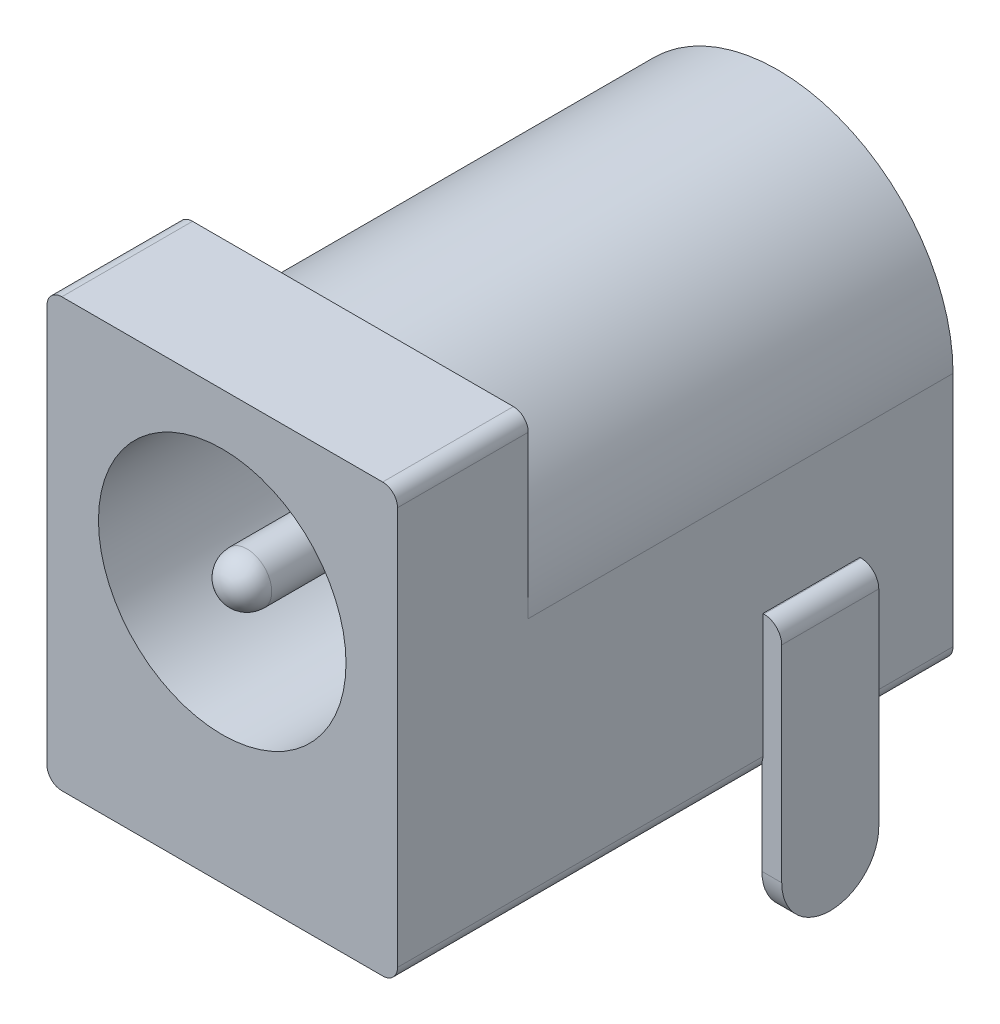
from build123d import *

# Parameters (mm, degrees)
BASE_EXTRUDE_DEPTH       = 14.2494
SKETCH2_R                = 3.175
SKETCH2_R_2              = 0.635
CUT_EXTRUDE1_DEPTH       = 11.7094
FILLET1_R                = 0.635
CUT_EXTRUDE2_DEPTH       = 10.8966
SKETCH4_W                = 0.508
SKETCH4_H                = 2.4892
SKETCH4_W_2              = 2.9972
SKETCH4_H_2              = 0.508
SKETCH4_W_3              = 2.4892
SKETCH4_H_3              = 0.254
BOSS_EXTRUDE1_DEPTH      = 3.683
BOSS_EXTRUDE1_DEPTH_BACK = 3.556
FILLET2_R                = 0.4572
CUT_EXTRUDE3_DEPTH       = 0.508
CUT_EXTRUDE4_DEPTH       = 0.508
CUT_EXTRUDE5_DEPTH       = 0.508


with BuildPart() as part:
    # Sketch1 → Base-Extrude (new body)
    with BuildSketch(Plane.XY):
        with BuildLine():
            Line((0.381, 0), (8.6106, 0))
            ThreePointArc((8.6106, 0), (8.880007684, 0.111592316), (8.9916, 0.381))
            Line((8.9916, 0.381), (8.9916, 10.5918))
            ThreePointArc((8.9916, 10.5918), (8.880007684, 10.861207684), (8.6106, 10.9728))
            Line((8.6106, 10.9728), (0.381, 10.9728))
            ThreePointArc((0.381, 10.9728), (0.111592316, 10.861207684), (0, 10.5918))
            Line((0, 10.5918), (0, 0.381))
            ThreePointArc((0, 0.381), (0.111592316, 0.111592316), (0.381, 0))
        make_face()
    extrude(amount=BASE_EXTRUDE_DEPTH)

    # Sketch2 → Cut-Extrude1 (cut)
    with BuildSketch(Plane.XY.offset(14.2494)):
        with Locations((4.4958, 6.477)):
            Circle(SKETCH2_R)
        with Locations((4.4958, 6.477)):
            Circle(SKETCH2_R_2, mode=Mode.SUBTRACT)
    extrude(amount=-CUT_EXTRUDE1_DEPTH, mode=Mode.SUBTRACT)

    # Fillet1
    fillet1_edges = [part.edges().sort_by_distance(p)[0] for p in [
        (3.8608, 6.477, 14.2494),
    ]]
    fillet(fillet1_edges, radius=FILLET1_R)

    # Sketch3 → Cut-Extrude2 (cut)
    with BuildSketch(Plane(origin=(0, 0, 0), x_dir=(-1, 0, 0), z_dir=(0, 0, -1))):
        with BuildLine():
            Line((-0.381, 10.9728), (-8.6106, 10.9728))
            ThreePointArc((-8.6106, 10.9728), (-8.880007684, 10.861207684), (-8.9916, 10.5918))
            Line((-8.9916, 10.5918), (-8.9916, 6.4516))
            ThreePointArc((-8.9916, 6.4516), (-4.4958, 10.9474), (0, 6.4516))
            Line((0, 6.4516), (0, 10.5918))
            ThreePointArc((0, 10.5918), (-0.111592316, 10.861207684), (-0.381, 10.9728))
        make_face()
    extrude(amount=-CUT_EXTRUDE2_DEPTH, mode=Mode.SUBTRACT)

    # Sketch4 → Boss-Extrude1 (add, two sides)
    with BuildSketch(Plane.XZ) as boss_extrude1_sk:
        with Locations((9.2202, 3.6322)):
            Rectangle(SKETCH4_W, SKETCH4_H)
        with Locations((4.4958, 0.635)):
            Rectangle(SKETCH4_W_2, SKETCH4_H_2)
        with Locations((4.4958, 6.8834)):
            Rectangle(SKETCH4_W_3, SKETCH4_H_3)
    extrude(amount=BOSS_EXTRUDE1_DEPTH)
    extrude(boss_extrude1_sk.sketch, amount=-BOSS_EXTRUDE1_DEPTH_BACK)

    # Fillet2
    fillet2_edges = [part.edges().sort_by_distance(p)[0] for p in [
        (9.4742, 3.556, 3.6322),
    ]]
    fillet(fillet2_edges, radius=FILLET2_R)

    # Sketch5 → Cut-Extrude3 (cut)
    with BuildSketch(Plane(origin=(0, 0, 0.381), x_dir=(-1, 0, 0), z_dir=(0, 0, -1))):
        with BuildLine():
            Line((-2.9972, -3.683), (-5.9944, -3.683))
            Line((-5.9944, -3.683), (-5.9944, -1.9304))
            ThreePointArc((-5.9944, -1.9304), (-4.4958, -3.429), (-2.9972, -1.9304))
            Line((-2.9972, -1.9304), (-2.9972, -3.683))
        make_face()
    extrude(amount=-CUT_EXTRUDE3_DEPTH, mode=Mode.SUBTRACT)

    # Sketch6 → Cut-Extrude4 (cut)
    with BuildSketch(Plane(origin=(0.312334932, -0.354120005, 6.7564), x_dir=(-1, 0, 0), z_dir=(0, 0, -1))):
        with BuildLine():
            Line((-2.938865068, -3.328879995), (-5.428065068, -3.328879995))
            Line((-5.428065068, -3.328879995), (-5.428065068, -1.830279995))
            ThreePointArc((-5.428065068, -1.830279995), (-4.183465068, -3.074879995), (-2.938865068, -1.830279995))
            Line((-2.938865068, -1.830279995), (-2.938865068, -3.328879995))
        make_face()
    extrude(amount=-CUT_EXTRUDE4_DEPTH, mode=Mode.SUBTRACT)

    # Sketch7 → Cut-Extrude5 (cut)
    with BuildSketch(Plane(origin=(9.4742, 0, 0), x_dir=(0, 0, -1), z_dir=(1, 0, 0))):
        with BuildLine():
            Line((-2.3876, -3.683), (-2.3876, -2.1844))
            ThreePointArc((-2.3876, -2.1844), (-3.6322, -3.429), (-4.8768, -2.1844))
            Line((-4.8768, -2.1844), (-4.8768, -3.683))
            Line((-4.8768, -3.683), (-2.3876, -3.683))
        make_face()
    extrude(amount=-CUT_EXTRUDE5_DEPTH, mode=Mode.SUBTRACT)


solid = part.part
